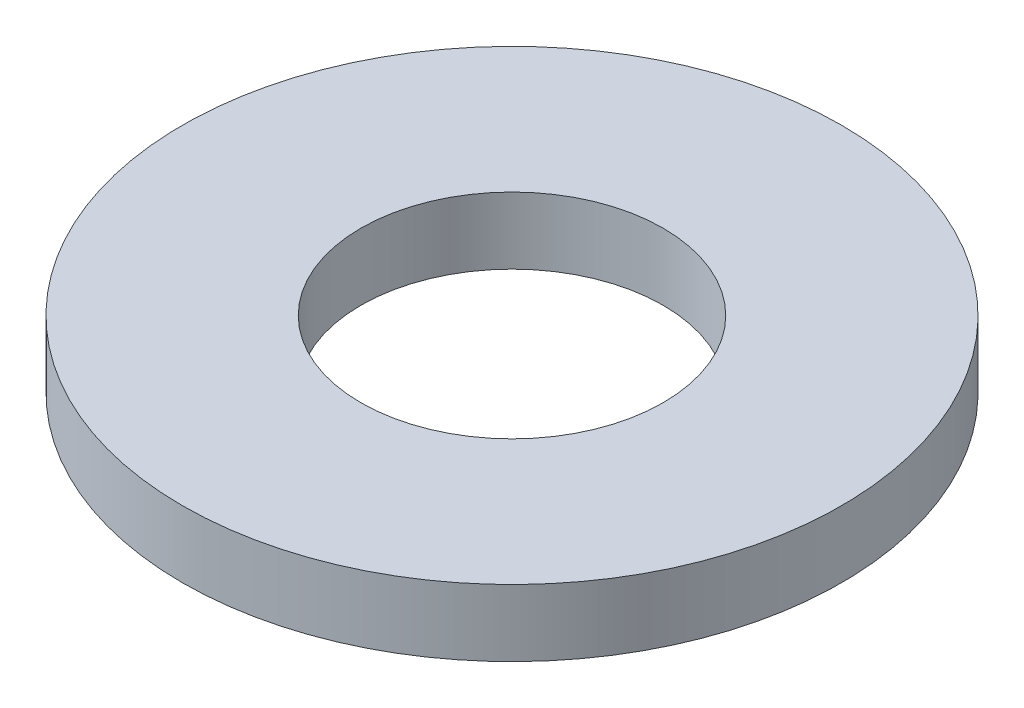
from build123d import *

# Parameters (mm, degrees)
SKETCH1_R           = 4.7625
BOSS_EXTRUDE1_DEPTH = 0.9652
SKETCH5_R           = 2.1844
CUT_EXTRUDE1_DEPTH  = 1.9652


with BuildPart() as part:
    # Sketch1 → Boss-Extrude1 (new body)
    with BuildSketch(Plane(origin=(0, 0, 0), x_dir=(1, 0, 0), z_dir=(0, 1, 0))):
        Circle(SKETCH1_R)
    extrude(amount=BOSS_EXTRUDE1_DEPTH)

    # Sketch5 → Cut-Extrude1 (cut, through all)
    with BuildSketch(Plane(origin=(0, 0.9652, 0), x_dir=(-1, 0, 0), z_dir=(0, 1, 0))):
        Circle(SKETCH5_R)
    extrude(amount=-CUT_EXTRUDE1_DEPTH, mode=Mode.SUBTRACT)


solid = part.part
